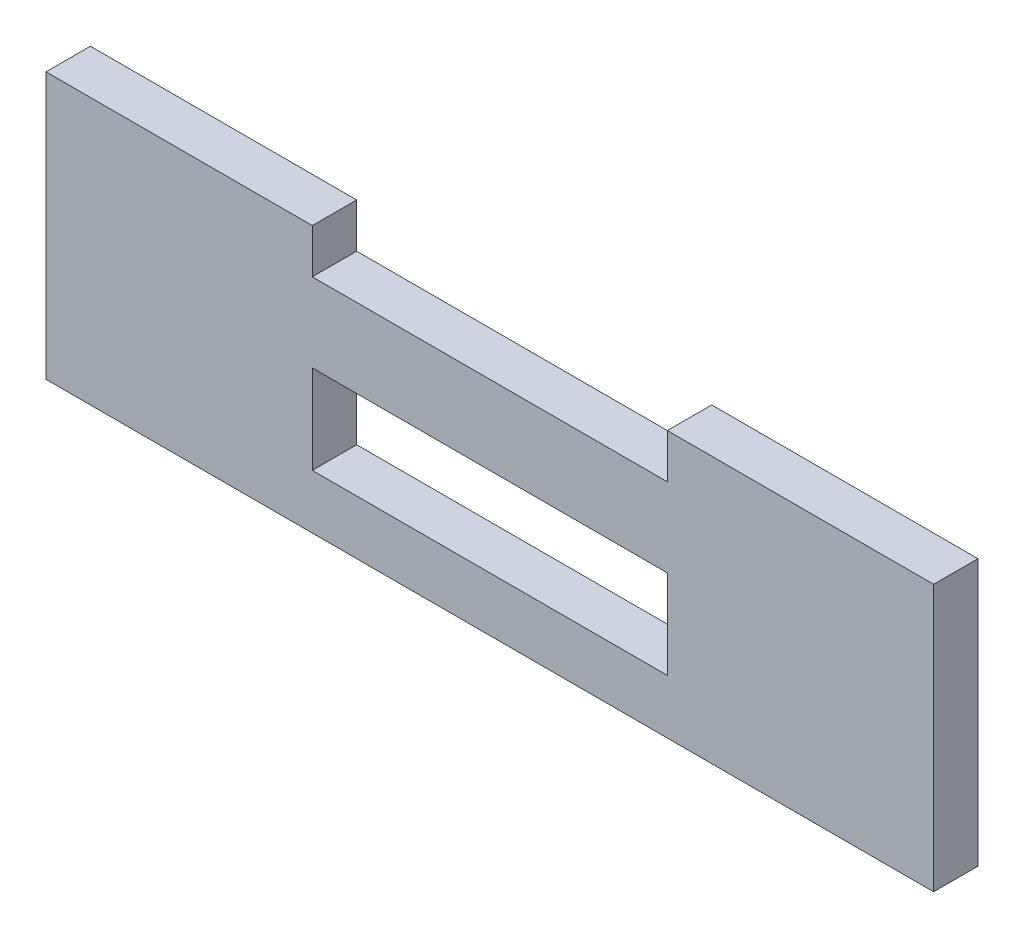
from build123d import *

# Parameters (mm, degrees)
BOSS_EXTRUDE1_DEPTH = 5
SKETCH2_W           = 40
SKETCH2_H           = 10
CUT_EXTRUDE1_DEPTH  = 5


with BuildPart() as part:
    # Sketch1 → Boss-Extrude1 (new body)
    with BuildSketch(Plane.XY):
        Polygon((-50, -26.114503221), (50, -26.114503221), (50, 3.885496779), (20, 3.885496779), (20, -1.114503221), (-20, -1.114503221), (-20, 3.885496779), (-50, 3.885496779), align=None)
    extrude(amount=BOSS_EXTRUDE1_DEPTH)

    # Sketch2 → Cut-Extrude1 (cut)
    with BuildSketch(Plane.XY.offset(5)):
        with Locations((0, -15)):
            Rectangle(SKETCH2_W, SKETCH2_H)
    extrude(amount=-CUT_EXTRUDE1_DEPTH, mode=Mode.SUBTRACT)


solid = part.part
